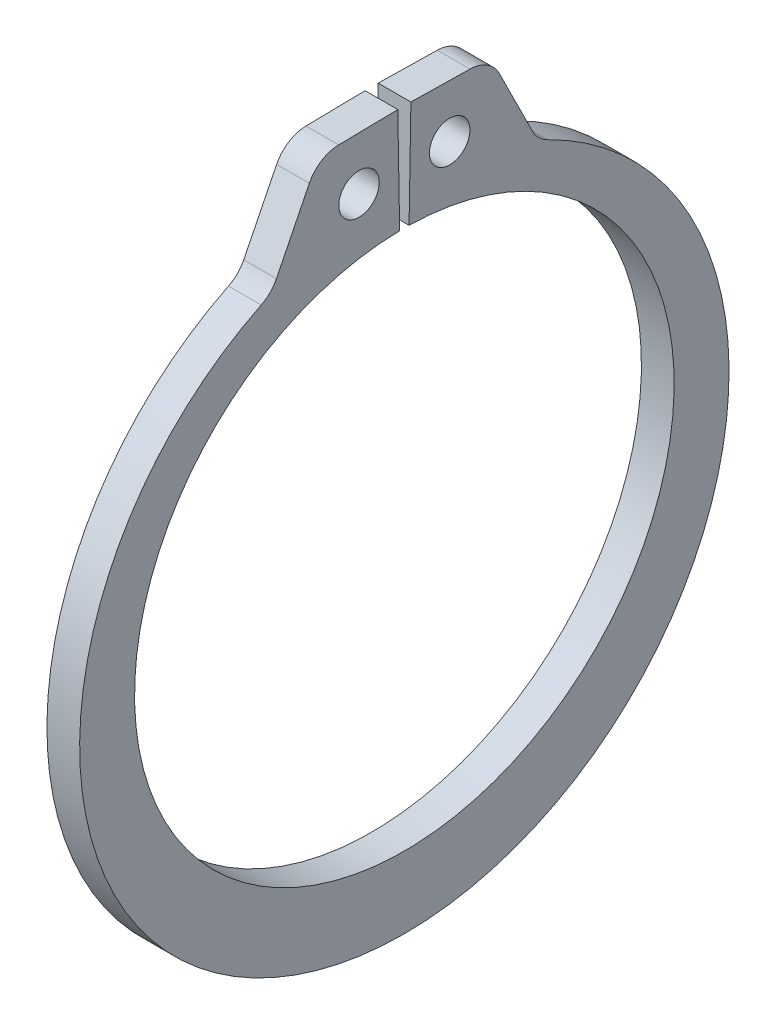
from build123d import *

# Parameters (mm, degrees)
SKETCH1_R      = 0.6604
EXTRUDE1_DEPTH = 0.5334
FILLET1_R      = 1.0922


with BuildPart() as part:
    # Sketch1 → Extrude1 (new body, symmetric)
    with BuildSketch(Plane(origin=(0, 0, 0), x_dir=(0, 0, -1), z_dir=(1, 0, 0))):
        with BuildLine():
            Line((-0.153600374, 8.79975955), (-0.213887967, 12.253633428))
            Line((-0.213887967, 12.253633428), (-2.804293376, 12.208417733))
            Line((-2.804293376, 12.208417733), (-4.342027289, 9.115158324))
            ThreePointArc((-4.342027289, 9.115158324), (0, -11.1379), (4.342027289, 9.115158324))
            Line((4.342027289, 9.115158324), (2.804293376, 12.208417733))
            Line((2.804293376, 12.208417733), (0.213887967, 12.253633428))
            Line((0.213887967, 12.253633428), (0.153600374, 8.79975955))
            ThreePointArc((0.153600374, 8.79975955), (0, -8.8011), (-0.153600374, 8.79975955))
        make_face()
        with Locations((-1.478946875, 10.504088642)):
            Circle(SKETCH1_R, mode=Mode.SUBTRACT)
        with Locations((1.478946875, 10.504088642)):
            Circle(SKETCH1_R, mode=Mode.SUBTRACT)
    extrude(amount=EXTRUDE1_DEPTH, both=True)

    # Fillet1
    fillet1_edges = [part.edges().sort_by_distance(p)[0] for p in [
        (0, 12.208417733, -2.804293376),
        (0, 9.115158324, -4.342027289),
        (0, 9.115158324, 4.342027289),
        (0, 12.208417733, 2.804293376),
    ]]
    fillet(fillet1_edges, radius=FILLET1_R)


solid = part.part
